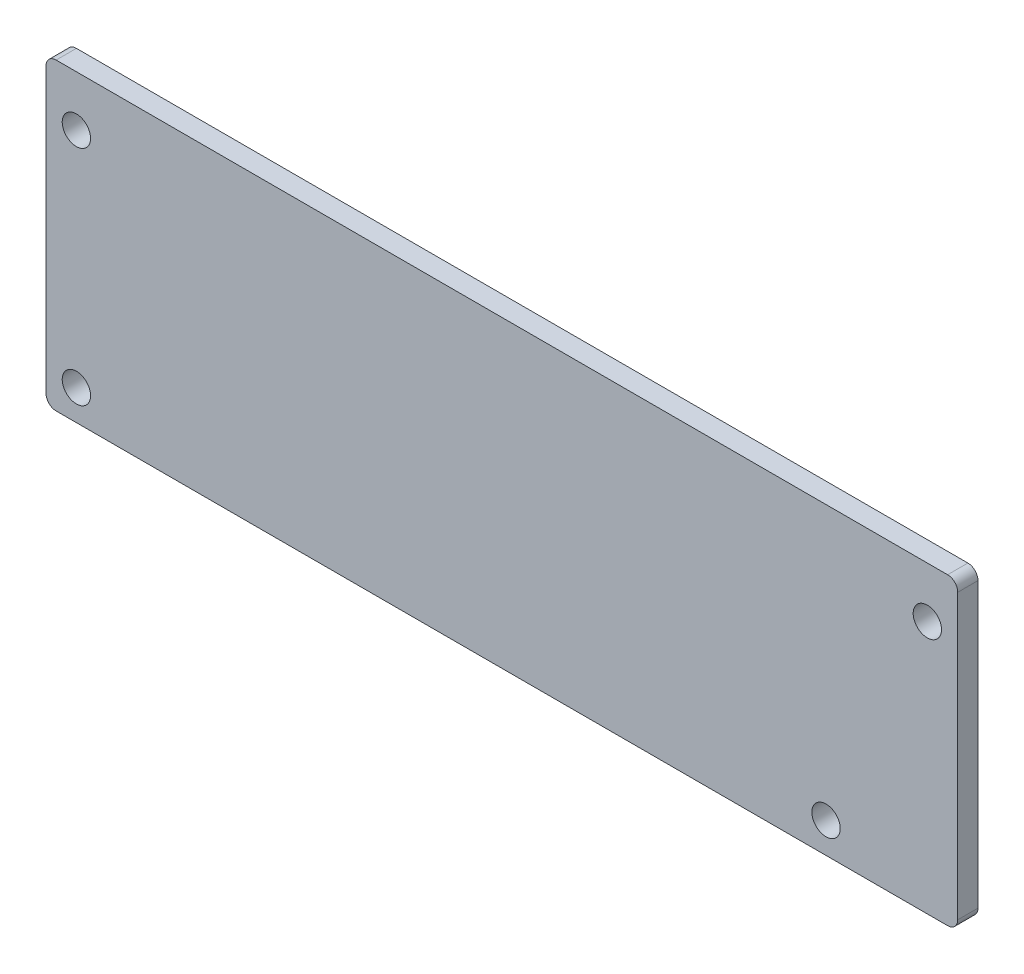
from build123d import *

# Parameters (mm, degrees)
SKETCH_1_R          = 1.4
EXTRUDE_1_DEPTH     = 2
CUT_EXTRUDE_1_DEPTH = 1


with BuildPart() as part:
    # Эскиз1 → Бобышка-Вытянуть1 (new body)
    with BuildSketch(Plane.XY):
        with BuildLine():
            Line((78, 0), (89, 0))
            ThreePointArc((89, 0), (89.707106781, 0.292893219), (90, 1))
            Line((90, 1), (90, 12))
            Line((90, 12), (90, 29))
            ThreePointArc((90, 29), (89.707106781, 29.707106781), (89, 30))
            Line((89, 30), (1, 30))
            ThreePointArc((1, 30), (0.292893219, 29.707106781), (0, 29))
            Line((0, 29), (0, 1))
            ThreePointArc((0, 1), (0.292893219, 0.292893219), (1, 0))
            Line((1, 0), (60.966683233, 0))
            Line((60.966683233, 0), (78, 0))
        make_face()
        with Locations((3, 3)):
            Circle(SKETCH_1_R, mode=Mode.SUBTRACT)
        with Locations((3, 25)):
            Circle(SKETCH_1_R, mode=Mode.SUBTRACT)
        with Locations((87, 25)):
            Circle(SKETCH_1_R, mode=Mode.SUBTRACT)
        with Locations((77, 3)):
            Circle(SKETCH_1_R, mode=Mode.SUBTRACT)
    extrude(amount=EXTRUDE_1_DEPTH)

    # Эскиз2 → Вырез-Вытянуть1 (cut)
    with BuildSketch(Plane(origin=(0, 0, 0), x_dir=(-1, 0, 0), z_dir=(0, 0, -1))):
        with BuildLine():
            Line((-82, 28), (-8, 28))
            ThreePointArc((-8, 28), (-7.292893219, 27.707106781), (-7, 27))
            Line((-7, 27), (-7, 23))
            ThreePointArc((-7, 23), (-6.707106781, 22.292893219), (-6, 22))
            Line((-6, 22), (-3, 22))
            ThreePointArc((-3, 22), (-2.292893219, 21.707106781), (-2, 21))
            Line((-2, 21), (-2, 8))
            ThreePointArc((-2, 8), (-2.292893219, 7.292893219), (-3, 7))
            Line((-3, 7), (-6, 7))
            ThreePointArc((-6, 7), (-6.707106781, 6.707106781), (-7, 6))
            Line((-7, 6), (-7, 3))
            ThreePointArc((-7, 3), (-7.292893219, 2.292893219), (-8, 2))
            Line((-8, 2), (-72, 2))
            ThreePointArc((-72, 2), (-72.707106781, 2.292893219), (-73, 3))
            Line((-73, 3), (-73, 6))
            ThreePointArc((-73, 6), (-73.292893219, 6.707106781), (-74, 7))
            Line((-74, 7), (-78.5, 7))
            ThreePointArc((-78.5, 7), (-79.207106781, 6.707106781), (-79.5, 6))
            Line((-79.5, 6), (-79.5, 2.5))
            ThreePointArc((-79.5, 2.5), (-79.792893219, 1.792893219), (-80.5, 1.5))
            Line((-80.5, 1.5), (-87.5, 1.5))
            ThreePointArc((-87.5, 1.5), (-88.207106781, 1.792893219), (-88.5, 2.5))
            Line((-88.5, 2.5), (-88.5, 21))
            ThreePointArc((-88.5, 21), (-88.207106781, 21.707106781), (-87.5, 22))
            Line((-87.5, 22), (-84, 22))
            ThreePointArc((-84, 22), (-83.292893219, 22.292893219), (-83, 23))
            Line((-83, 23), (-83, 27))
            ThreePointArc((-83, 27), (-82.707106781, 27.707106781), (-82, 28))
        make_face()
    extrude(amount=-CUT_EXTRUDE_1_DEPTH, mode=Mode.SUBTRACT)


solid = part.part
